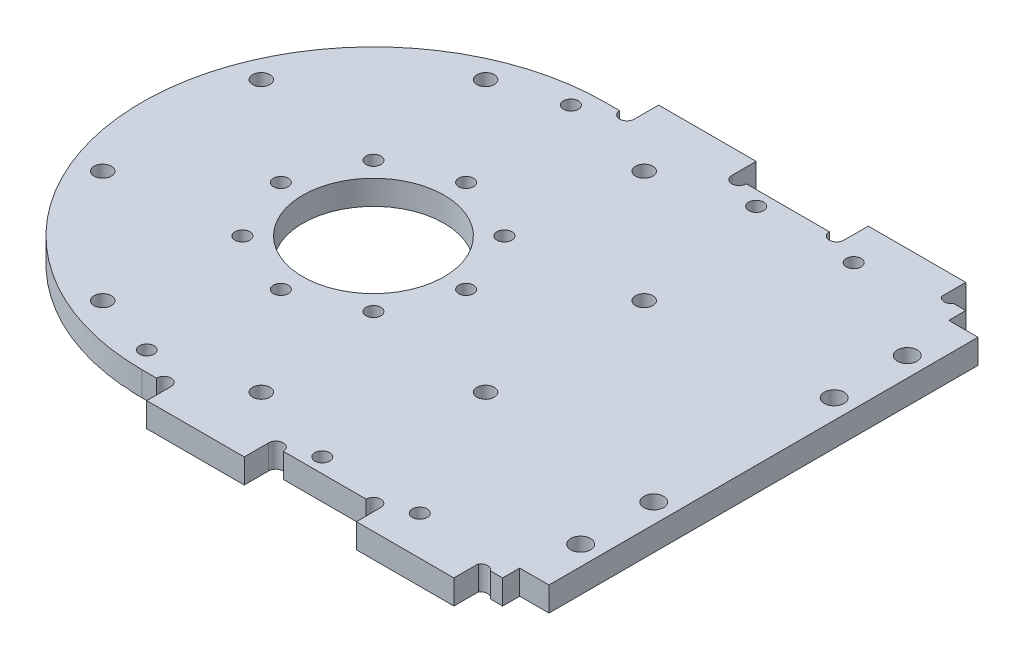
from build123d import *

# Parameters (mm, degrees)
EXTRUDE_1_DEPTH           = 2.5
FILLET_1_R                = 3
SKETCH_2_R                = 1.775
CUT_EXTRUDE_1_DEPTH       = 1
CUT_EXTRUDE_1_DEPTH_BACK  = 6
SKETCH_4_R                = 2.025
CUT_EXTRUDE_3_DEPTH       = 1
CUT_EXTRUDE_3_DEPTH_BACK  = 6
SKETCH_12_W               = 6
SKETCH_12_H               = 3.5
CUT_EXTRUDE_9_DEPTH       = 10
SKETCH_14_W               = 20
SKETCH_14_H               = 5
EXTRUDE_3_DEPTH           = 5
CUT_EXTRUDE_10_DEPTH      = 5
CUT_EXTRUDE_START         = -6
SKETCH_16_R               = 1.525
CUT_EXTRUDE_11_DEPTH      = 7
SKETCH_18_R               = 1.525
CUT_EXTRUDE_13_DEPTH      = 8
HOLE_WIZARD_1_D           = 3
HOLE_WIZARD_1_CSINK_D     = 8
HOLE_WIZARD_1_CSINK_ANGLE = 90
SKETCH_20_R               = 1.525
CUT_EXTRUDE_14_DEPTH      = 6.0000001
SKETCH_21_R               = 14.5
CUT_EXTRUDE_15_DEPTH      = 6.0000001


with BuildPart() as part:
    # 草图1 → 凸台-拉伸1 (new body, symmetric)
    with BuildSketch(Plane(origin=(0, 0, 0), x_dir=(1, 0, 0), z_dir=(0, 1, 0))):
        with BuildLine():
            Line((0, 47.5), (80, 47.5))
            Line((80, 47.5), (80, -47.5))
            Line((80, -47.5), (0, -47.5))
            ThreePointArc((0, -47.5), (-47.5, 0), (0, 47.5))
        make_face()
    extrude(amount=EXTRUDE_1_DEPTH, both=True)

    # 圆角1
    fillet_1_edges = [part.edges().sort_by_distance(p)[0] for p in [
        (80, 0, -47.5),
        (80, 0, 47.5),
    ]]
    fillet(fillet_1_edges, radius=FILLET_1_R)

    # 草图2 → 切除-拉伸1 (cut, two sides)
    with BuildSketch(Plane(origin=(0, 2.5, 0), x_dir=(1, 0, 0), z_dir=(0, 1, 0))) as cut_extrude_1_sk:
        with Locations((-39.264880132, 16.264045876)):
            Circle(SKETCH_2_R)
        with Locations((-16.264045876, 39.264880132)):
            Circle(SKETCH_2_R)
        with Locations((16.264045876, 39.264880132)):
            Circle(SKETCH_2_R)
        with Locations((39.264880132, 16.264045876)):
            Circle(SKETCH_2_R)
        with Locations((39.264880132, -16.264045876)):
            Circle(SKETCH_2_R)
        with Locations((16.264045876, -39.264880132)):
            Circle(SKETCH_2_R)
        with Locations((-16.264045876, -39.264880132)):
            Circle(SKETCH_2_R)
        with Locations((-39.264880132, -16.264045876)):
            Circle(SKETCH_2_R)
    extrude(amount=CUT_EXTRUDE_1_DEPTH, mode=Mode.SUBTRACT)
    extrude(cut_extrude_1_sk.sketch, amount=-CUT_EXTRUDE_1_DEPTH_BACK, mode=Mode.SUBTRACT)

    # 草图4 → 切除-拉伸3 (cut, two sides)
    with BuildSketch(Plane(origin=(0, 2.5, 0), x_dir=(1, 0, 0), z_dir=(0, 1, 0))) as cut_extrude_3_sk:
        with Locations((76, -33.5)):
            Circle(SKETCH_4_R)
        with Locations((76, 33.5)):
            Circle(SKETCH_4_R)
        with Locations((76, 18.5)):
            Circle(SKETCH_4_R)
        with Locations((76, -18.5)):
            Circle(SKETCH_4_R)
    extrude(amount=CUT_EXTRUDE_3_DEPTH, mode=Mode.SUBTRACT)
    extrude(cut_extrude_3_sk.sketch, amount=-CUT_EXTRUDE_3_DEPTH_BACK, mode=Mode.SUBTRACT)

    # 草图12 → 切除-拉伸9 (cut)
    with BuildSketch(Plane(origin=(0, 2.5, 0), x_dir=(1, 0, 0), z_dir=(0, 1, 0))):
        with Locations((77, -45.75)):
            Rectangle(SKETCH_12_W, SKETCH_12_H)
    cut_extrude_9 = extrude(amount=-CUT_EXTRUDE_9_DEPTH, mode=Mode.SUBTRACT)

    # 草图14 → 凸台-拉伸3 (add)
    with BuildSketch(Plane.XY.offset(47.5)):
        with Locations((59, 0)):
            Rectangle(SKETCH_14_W, SKETCH_14_H)
        with Locations((16, 0)):
            Rectangle(SKETCH_14_W, SKETCH_14_H)
    extrude_3 = extrude(amount=EXTRUDE_3_DEPTH)

    # 草图15 → 切除-拉伸10 (cut)
    with BuildSketch(Plane(origin=(0, 2.5, 0), x_dir=(1, 0, 0), z_dir=(0, 1, 0))):
        with BuildLine():
            Line((26, -47.5), (29, -47.5))
            ThreePointArc((29, -47.5), (27.5, -46), (26, -47.5))
        make_face()
        with BuildLine():
            Line((46, -47.5), (49, -47.5))
            ThreePointArc((49, -47.5), (47.5, -46), (46, -47.5))
        make_face()
        with BuildLine():
            Line((71.5, -47.5), (69, -47.5))
            ThreePointArc((69, -47.5), (70.25, -46.829156198), (71.5, -47.5))
        make_face()
        with BuildLine():
            Line((3, -47.5), (6, -47.5))
            ThreePointArc((6, -47.5), (4.5, -46), (3, -47.5))
        make_face()
    cut_extrude_10 = extrude(amount=-CUT_EXTRUDE_10_DEPTH, mode=Mode.SUBTRACT)

    # 镜向4: 凸台-拉伸3 across plane
    add(extrude_3.mirror(Plane.XY))

    # 草图16 → 切除-拉伸11 (cut)
    with BuildSketch(Plane(origin=(0, 2.5, 0), x_dir=(1, 0, 0), z_dir=(0, 1, 0)).offset(CUT_EXTRUDE_START)):
        with Locations((34, -44.5)):
            Circle(SKETCH_16_R)
        with Locations((54, -44.5)):
            Circle(SKETCH_16_R)
    cut_extrude_11 = extrude(amount=CUT_EXTRUDE_11_DEPTH, mode=Mode.SUBTRACT)

    # 镜向5: 切除-拉伸9, 切除-拉伸10, 切除-拉伸11 across plane
    add(cut_extrude_9.mirror(Plane.XY), mode=Mode.SUBTRACT)
    add(cut_extrude_10.mirror(Plane.XY), mode=Mode.SUBTRACT)
    add(cut_extrude_11.mirror(Plane.XY), mode=Mode.SUBTRACT)

    # 草图18 → 切除-拉伸13 (cut)
    with BuildSketch(Plane(origin=(0, 2.5, 0), x_dir=(1, 0, 0), z_dir=(0, 1, 0))):
        with Locations((-3, 43.5)):
            Circle(SKETCH_18_R)
    extrude(amount=-CUT_EXTRUDE_13_DEPTH, mode=Mode.SUBTRACT)

    # 孔1 (through all)
    with Locations(Plane(origin=(-3, -2.5, -43.5), x_dir=(0, 0, -1), z_dir=(0, -1, 0))):
        with Locations((0, 0)):
            hole_wizard_1 = CounterSinkHole(HOLE_WIZARD_1_D / 2, HOLE_WIZARD_1_CSINK_D / 2, counter_sink_angle=HOLE_WIZARD_1_CSINK_ANGLE)

    # 镜向6: 孔1 across plane
    add(hole_wizard_1.mirror(Plane.XY), mode=Mode.SUBTRACT)

    # 草图20 → 切除-拉伸14 (cut, through all)
    with BuildSketch(Plane(origin=(0, 2.5, 0), x_dir=(1, 0, 0), z_dir=(0, 1, 0))):
        with Locations((-13.435028843, 13.435028843)):
            Circle(SKETCH_20_R)
        with Locations((0, 19)):
            Circle(SKETCH_20_R)
        with Locations((13.435028843, 13.435028843)):
            Circle(SKETCH_20_R)
        with Locations((19, 0)):
            Circle(SKETCH_20_R)
        with Locations((13.435028843, -13.435028843)):
            Circle(SKETCH_20_R)
        with Locations((0, -19)):
            Circle(SKETCH_20_R)
        with Locations((-13.435028843, -13.435028843)):
            Circle(SKETCH_20_R)
        with Locations((-19, 0)):
            Circle(SKETCH_20_R)
    extrude(amount=-CUT_EXTRUDE_14_DEPTH, mode=Mode.SUBTRACT)

    # 草图21 → 切除-拉伸15 (cut, through all)
    with BuildSketch(Plane.XZ.offset(2.5)):
        Circle(SKETCH_21_R)
    extrude(amount=-CUT_EXTRUDE_15_DEPTH, mode=Mode.SUBTRACT)


solid = part.part
